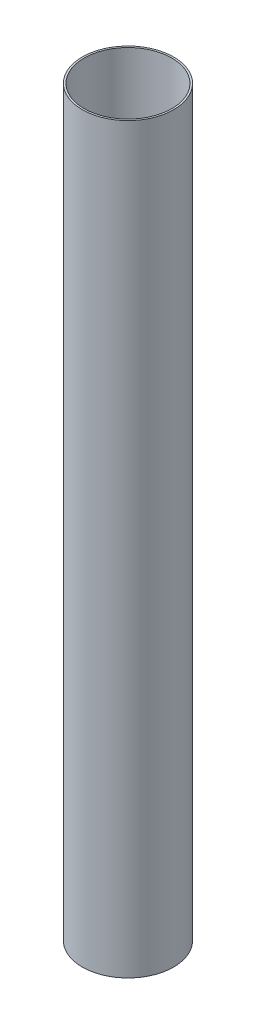
from build123d import *

# Parameters (mm, degrees)
SKETCH1_W = 2.0574
SKETCH1_H = 838.2


with BuildPart() as part:
    # Sketch1 → Revolve1 (revolve)
    with BuildSketch(Plane.XY):
        with Locations((50.5587, 419.1)):
            Rectangle(SKETCH1_W, SKETCH1_H)
    revolve(axis=Axis((0, 123.620053705, 0), (0, -1, 0)))


solid = part.part
